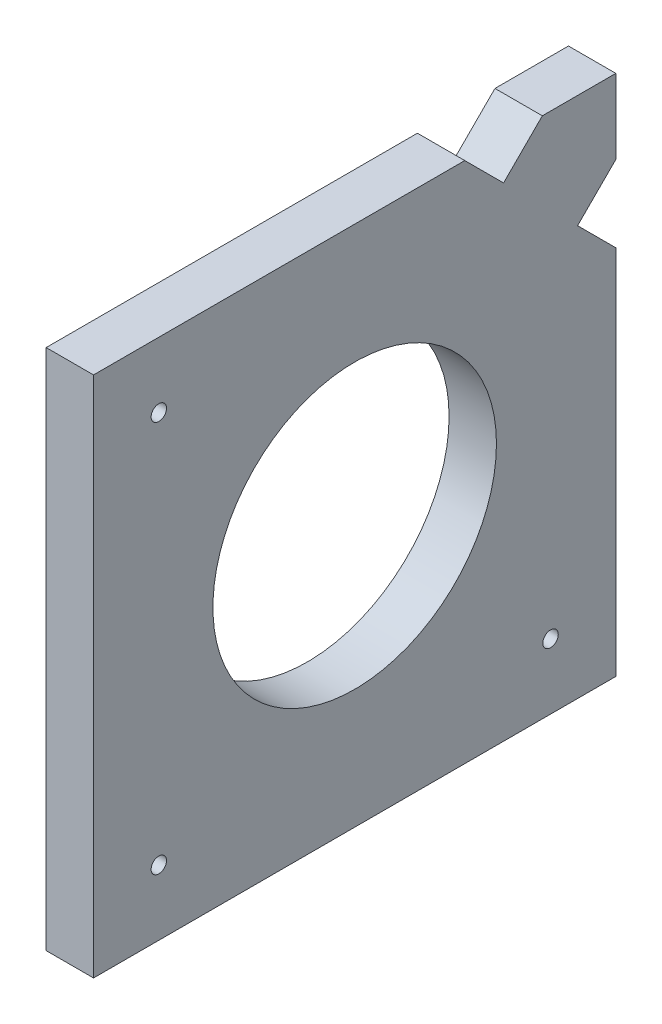
from build123d import *

# Parameters (mm, degrees)
SKETCH1_R           = 19
BOSS_EXTRUDE1_DEPTH = 6.35
SKETCH2_R           = 1.03251
CUT_EXTRUDE1_DEPTH  = 6.35


with BuildPart() as part:
    # Sketch1 → Boss-Extrude1 (new body)
    with BuildSketch(Plane(origin=(0, 0, 0), x_dir=(0, 0, -1), z_dir=(1, 0, 0))):
        Polygon((0, 0), (70, 0), (70, 49.756615014), (64.872483647, 54.884131367), (70, 60.011647719), (70, 70), (60.148635267, 70), (54.952625141, 64.803989874), (49.756615014, 70), (0, 70), align=None)
        with Locations((35, 35)):
            Circle(SKETCH1_R, mode=Mode.SUBTRACT)
    extrude(amount=BOSS_EXTRUDE1_DEPTH)

    # Sketch2 → Cut-Extrude1 (cut)
    with BuildSketch(Plane(origin=(6.35, 0, 0), x_dir=(0, 0, -1), z_dir=(1, 0, 0))):
        with Locations((8.75, 61.25)):
            Circle(SKETCH2_R)
        with Locations((8.75, 8.75)):
            Circle(SKETCH2_R)
        with Locations((61.25, 8.75)):
            Circle(SKETCH2_R)
    extrude(amount=-CUT_EXTRUDE1_DEPTH, mode=Mode.SUBTRACT)


solid = part.part
